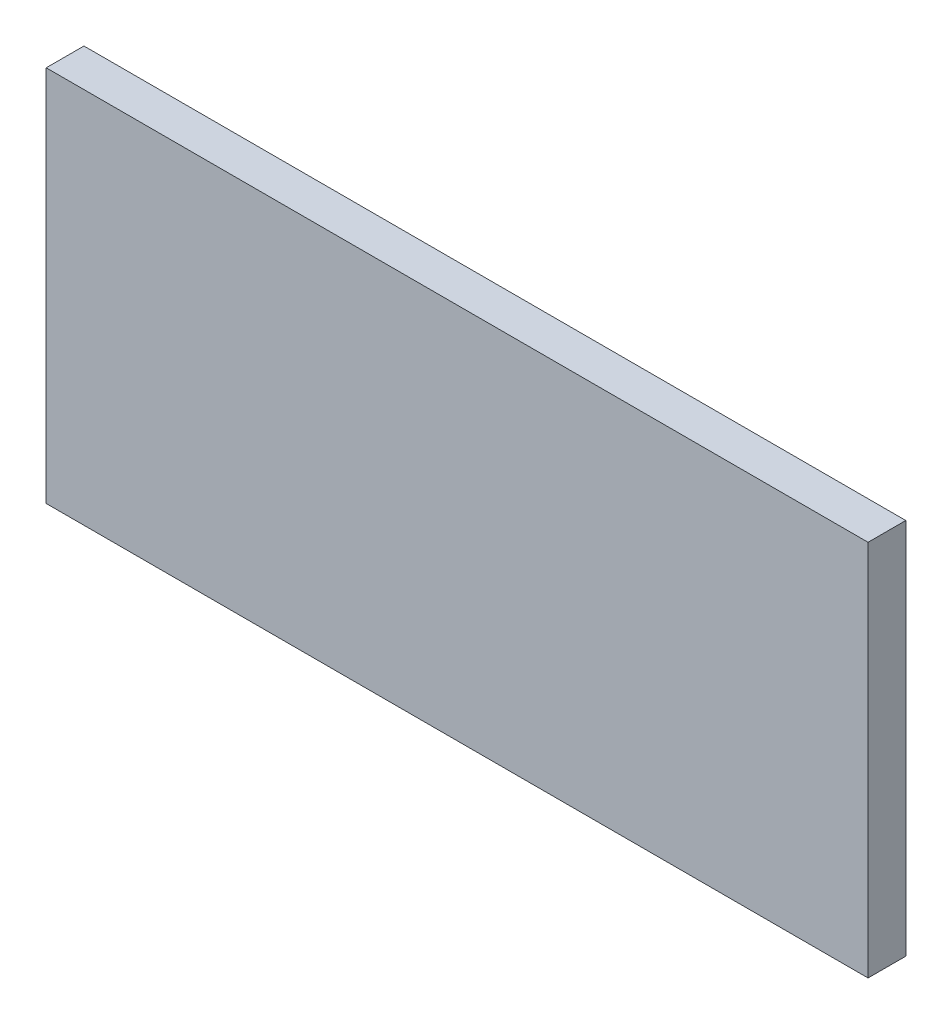
from build123d import *

# Parameters (mm, degrees)
SKETCH1_W           = 355
SKETCH1_H           = 163
BOSS_EXTRUDE1_DEPTH = 16.3


with BuildPart() as part:
    # Sketch1 → Boss-Extrude1 (new body)
    with BuildSketch(Plane.XY):
        Rectangle(SKETCH1_W, SKETCH1_H)
    extrude(amount=BOSS_EXTRUDE1_DEPTH)


solid = part.part
